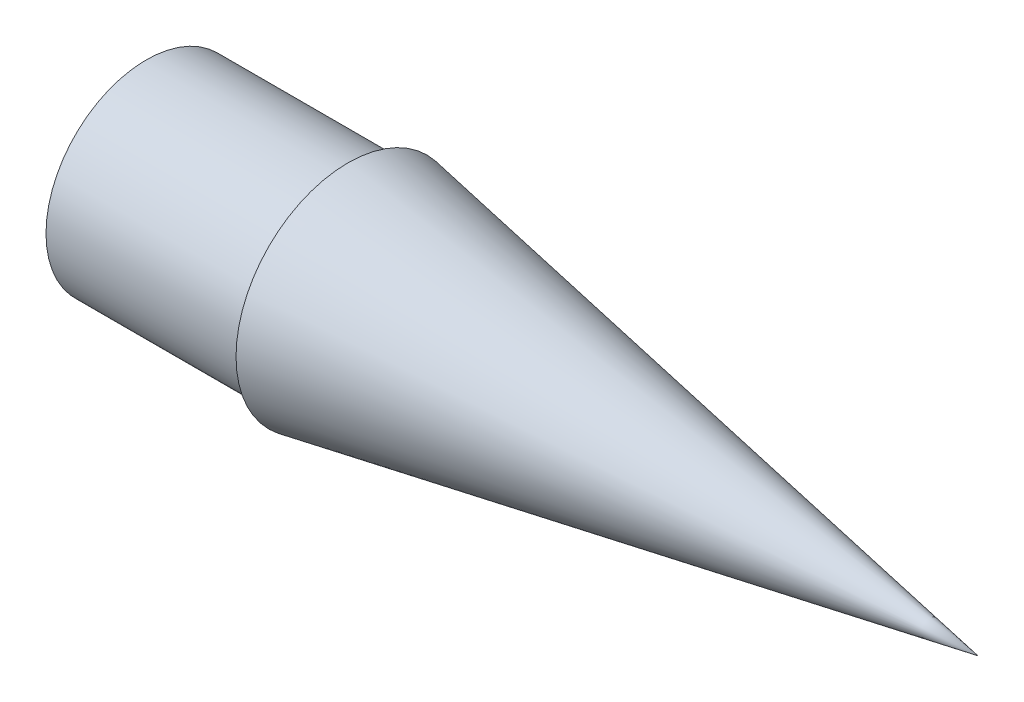
from build123d import *

# Parameters (mm, degrees)
SHELL1_T = -2.54


with BuildPart() as part:
    # Sketch1 → Revolve2 (revolve)
    with BuildSketch(Plane(origin=(0, 0, 0), x_dir=(1, 0, 0), z_dir=(0, 1, 0))):
        Polygon((0, 0), (0, 25.273), (50.8, 25.273), (50.8, 28.194), (209.55, 0), align=None)
    revolve(axis=Axis((0, 0, 0), (1, 0, 0)))

    # Shell1
    shell1_openings = [part.faces().sort_by_distance(p)[0] for p in [
        (0, 0, 25.273),
    ]]
    offset(amount=SHELL1_T, openings=shell1_openings, kind=Kind.INTERSECTION)


solid = part.part
